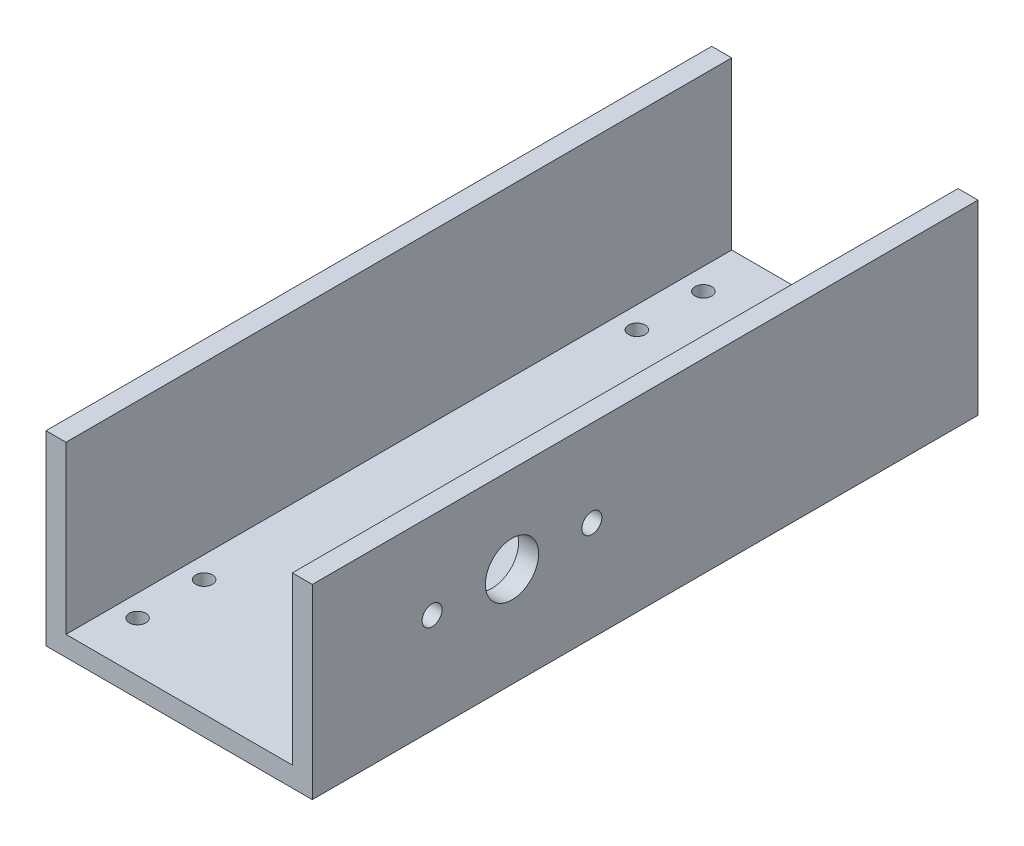
from build123d import *

# Parameters (mm, degrees)
EXTRUDE_1_DEPTH     = 200
CUT_EXTRUDE_1_REACH = 82
SKETCH_3_R          = 8
SKETCH_3_R_2        = 3
CUT_EXTRUDE_2_REACH = 58
SKETCH_4_R          = 2.5


with BuildPart() as part:
    # 草图1 → 凸台-拉伸1 (new body)
    with BuildSketch(Plane.XY):
        Polygon((-40, 0), (40, 0), (40, 56), (34, 56), (34, 6), (-34, 6), (-34, 56), (-40, 56), align=None)
    extrude(amount=EXTRUDE_1_DEPTH)

    # 草图3 → 切除-拉伸1 (cut, up to next)
    with BuildSketch(Plane(origin=(40, 0, 0), x_dir=(0, 0, -1), z_dir=(1, 0, 0)), mode=Mode.PRIVATE) as cut_extrude_1_sk1:
        with Locations((-140, 30)):
            Circle(SKETCH_3_R)
    cut_extrude_1_tool1 = extrude(cut_extrude_1_sk1.sketch, amount=-CUT_EXTRUDE_1_REACH, mode=Mode.PRIVATE) & part.part
    add(cut_extrude_1_tool1.solids().sort_by_distance((40, 30, 140))[0], mode=Mode.SUBTRACT)
    # 草图3 → 切除-拉伸1 (cut, up to next)
    with BuildSketch(Plane(origin=(40, 0, 0), x_dir=(0, 0, -1), z_dir=(1, 0, 0)), mode=Mode.PRIVATE) as cut_extrude_1_sk2:
        with Locations((-164, 30)):
            Circle(SKETCH_3_R_2)
    cut_extrude_1_tool2 = extrude(cut_extrude_1_sk2.sketch, amount=-CUT_EXTRUDE_1_REACH, mode=Mode.PRIVATE) & part.part
    add(cut_extrude_1_tool2.solids().sort_by_distance((40, 30, 164))[0], mode=Mode.SUBTRACT)
    # 草图3 → 切除-拉伸1 (cut, up to next)
    with BuildSketch(Plane(origin=(40, 0, 0), x_dir=(0, 0, -1), z_dir=(1, 0, 0)), mode=Mode.PRIVATE) as cut_extrude_1_sk3:
        with Locations((-116, 30)):
            Circle(SKETCH_3_R_2)
    cut_extrude_1_tool3 = extrude(cut_extrude_1_sk3.sketch, amount=-CUT_EXTRUDE_1_REACH, mode=Mode.PRIVATE) & part.part
    add(cut_extrude_1_tool3.solids().sort_by_distance((40, 30, 116))[0], mode=Mode.SUBTRACT)

    # 草图4 → 切除-拉伸2 (cut, up to next)
    with BuildSketch(Plane.XZ, mode=Mode.PRIVATE) as cut_extrude_2_sk1:
        with Locations((-27.5, 185)):
            Circle(SKETCH_4_R)
    cut_extrude_2_tool1 = extrude(cut_extrude_2_sk1.sketch, amount=-CUT_EXTRUDE_2_REACH, mode=Mode.PRIVATE) & part.part
    add(cut_extrude_2_tool1.solids().sort_by_distance((-27.5, 0, 185))[0], mode=Mode.SUBTRACT)
    # 草图4 → 切除-拉伸2 (cut, up to next)
    with BuildSketch(Plane.XZ, mode=Mode.PRIVATE) as cut_extrude_2_sk2:
        with Locations((27.5, 185)):
            Circle(SKETCH_4_R)
    cut_extrude_2_tool2 = extrude(cut_extrude_2_sk2.sketch, amount=-CUT_EXTRUDE_2_REACH, mode=Mode.PRIVATE) & part.part
    add(cut_extrude_2_tool2.solids().sort_by_distance((27.5, 0, 185))[0], mode=Mode.SUBTRACT)
    # 草图4 → 切除-拉伸2 (cut, up to next)
    with BuildSketch(Plane.XZ, mode=Mode.PRIVATE) as cut_extrude_2_sk3:
        with Locations((-27.5, 165)):
            Circle(SKETCH_4_R)
    cut_extrude_2_tool3 = extrude(cut_extrude_2_sk3.sketch, amount=-CUT_EXTRUDE_2_REACH, mode=Mode.PRIVATE) & part.part
    add(cut_extrude_2_tool3.solids().sort_by_distance((-27.5, 0, 165))[0], mode=Mode.SUBTRACT)
    # 草图4 → 切除-拉伸2 (cut, up to next)
    with BuildSketch(Plane.XZ, mode=Mode.PRIVATE) as cut_extrude_2_sk4:
        with Locations((27.5, 165)):
            Circle(SKETCH_4_R)
    cut_extrude_2_tool4 = extrude(cut_extrude_2_sk4.sketch, amount=-CUT_EXTRUDE_2_REACH, mode=Mode.PRIVATE) & part.part
    add(cut_extrude_2_tool4.solids().sort_by_distance((27.5, 0, 165))[0], mode=Mode.SUBTRACT)
    # 草图4 → 切除-拉伸2 (cut, up to next)
    with BuildSketch(Plane.XZ, mode=Mode.PRIVATE) as cut_extrude_2_sk5:
        with Locations((27.5, 35)):
            Circle(SKETCH_4_R)
    cut_extrude_2_tool5 = extrude(cut_extrude_2_sk5.sketch, amount=-CUT_EXTRUDE_2_REACH, mode=Mode.PRIVATE) & part.part
    add(cut_extrude_2_tool5.solids().sort_by_distance((27.5, 0, 35))[0], mode=Mode.SUBTRACT)
    # 草图4 → 切除-拉伸2 (cut, up to next)
    with BuildSketch(Plane.XZ, mode=Mode.PRIVATE) as cut_extrude_2_sk6:
        with Locations((-27.5, 35)):
            Circle(SKETCH_4_R)
    cut_extrude_2_tool6 = extrude(cut_extrude_2_sk6.sketch, amount=-CUT_EXTRUDE_2_REACH, mode=Mode.PRIVATE) & part.part
    add(cut_extrude_2_tool6.solids().sort_by_distance((-27.5, 0, 35))[0], mode=Mode.SUBTRACT)
    # 草图4 → 切除-拉伸2 (cut, up to next)
    with BuildSketch(Plane.XZ, mode=Mode.PRIVATE) as cut_extrude_2_sk7:
        with Locations((27.5, 15)):
            Circle(SKETCH_4_R)
    cut_extrude_2_tool7 = extrude(cut_extrude_2_sk7.sketch, amount=-CUT_EXTRUDE_2_REACH, mode=Mode.PRIVATE) & part.part
    add(cut_extrude_2_tool7.solids().sort_by_distance((27.5, 0, 15))[0], mode=Mode.SUBTRACT)
    # 草图4 → 切除-拉伸2 (cut, up to next)
    with BuildSketch(Plane.XZ, mode=Mode.PRIVATE) as cut_extrude_2_sk8:
        with Locations((-27.5, 15)):
            Circle(SKETCH_4_R)
    cut_extrude_2_tool8 = extrude(cut_extrude_2_sk8.sketch, amount=-CUT_EXTRUDE_2_REACH, mode=Mode.PRIVATE) & part.part
    add(cut_extrude_2_tool8.solids().sort_by_distance((-27.5, 0, 15))[0], mode=Mode.SUBTRACT)


solid = part.part
